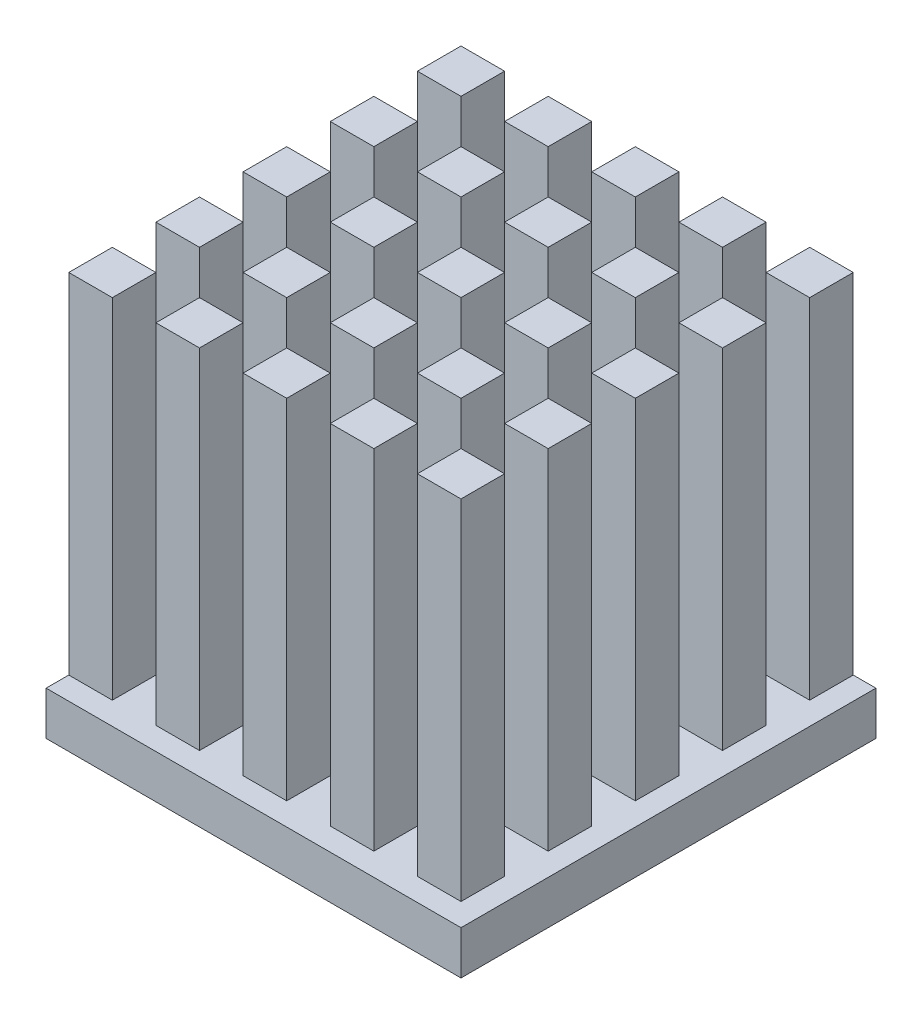
from build123d import *

# Parameters (mm, degrees)
SKETCH1_W            = 14.28
SKETCH1_H            = 14.28
BOSS_EXTRUDE1_DEPTH  = 1.5
SKETCH3_W            = 1.5
SKETCH3_H            = 1.5
BOSS_EXTRUDE3_DEPTH  = 12
LPATTERN2_COUNT      = 5
LPATTERN2_PITCH      = 3
LPATTERN2_COUNT_DIR2 = 5
LPATTERN2_PITCH_DIR2 = 3


with BuildPart() as part:
    # Sketch1 → Boss-Extrude1 (new body)
    with BuildSketch(Plane(origin=(0, 0, 0), x_dir=(1, 0, 0), z_dir=(0, 1, 0))):
        Rectangle(SKETCH1_W, SKETCH1_H)
    extrude(amount=BOSS_EXTRUDE1_DEPTH)

    # Sketch3 → Boss-Extrude3 (add)
    with BuildSketch(Plane(origin=(0, 1.5, 0), x_dir=(1, 0, 0), z_dir=(0, 1, 0))):
        with Locations((-6.39, 6.39)):
            Rectangle(SKETCH3_W, SKETCH3_H)
    boss_extrude3 = extrude(amount=BOSS_EXTRUDE3_DEPTH)

    # LPattern2: Boss-Extrude3 5 × 5
    with Locations(*[(i * LPATTERN2_PITCH, 0, j * LPATTERN2_PITCH_DIR2) for i in range(LPATTERN2_COUNT) for j in range(LPATTERN2_COUNT_DIR2) if (i, j) != (0, 0)]):
        add(boss_extrude3)


solid = part.part
